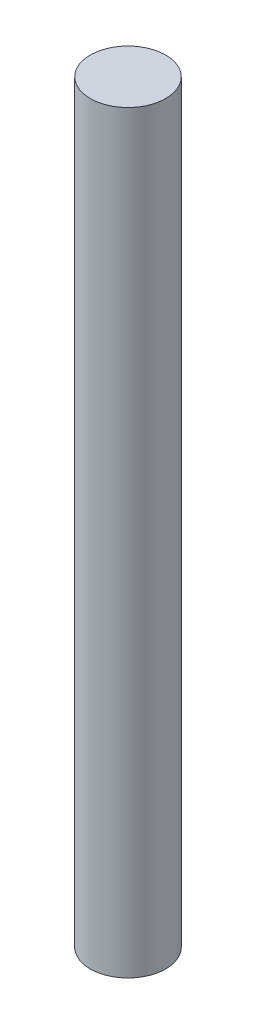
from build123d import *

# Parameters (mm, degrees)
SKETCH1_R           = 7.5
BOSS_EXTRUDE1_DEPTH = 75


with BuildPart() as part:
    # Sketch1 → Boss-Extrude1 (new body, symmetric)
    with BuildSketch(Plane(origin=(0, 0, 0), x_dir=(1, 0, 0), z_dir=(0, 1, 0))):
        Circle(SKETCH1_R)
    extrude(amount=BOSS_EXTRUDE1_DEPTH, both=True)


solid = part.part
